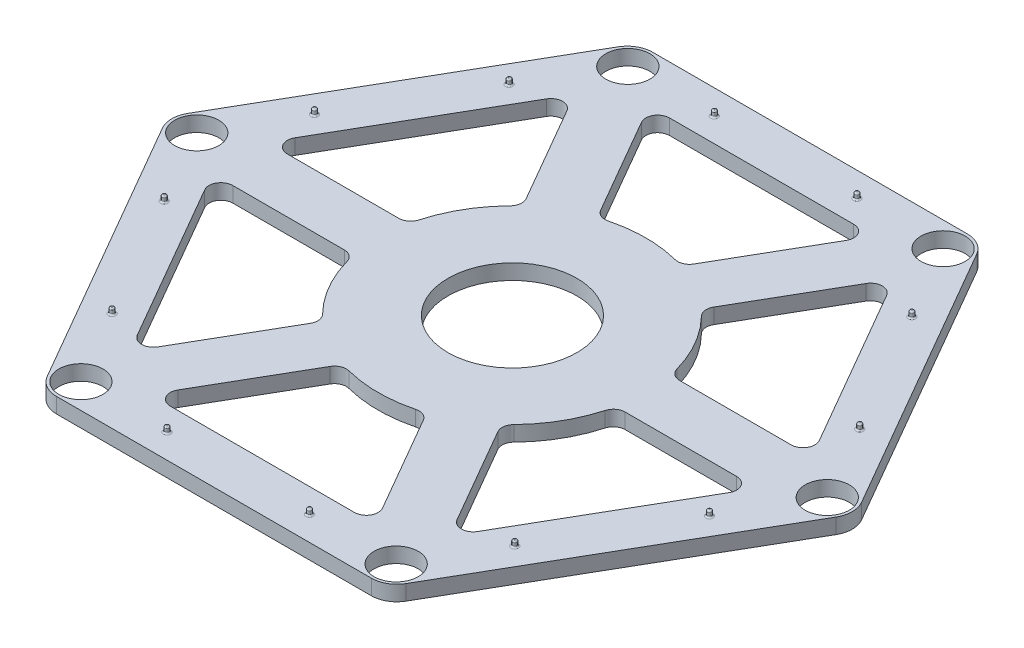
from build123d import *

# Parameters (mm, degrees)
SKETCH1_R           = 2.6
SKETCH1_R_2         = 7.6
BOSS_EXTRUDE1_DEPTH = 1.8
FILLET1_R           = 3
FILLET2_R           = 1.4
SCALE1_SCALE        = 1.15
SKETCH4_R           = 0.3
BOSS_EXTRUDE3_DEPTH = 0.8
FILLET5_R           = 0.2


with BuildPart() as part:
    # Sketch1 → Boss-Extrude1 (new body)
    with BuildSketch(Plane(origin=(0, 0, 0), x_dir=(1, 0, 0), z_dir=(0, 1, 0))):
        Polygon((20.3, 35.160631394), (-20.3, 35.160631394), (-40.6, 0), (-20.3, -35.160631394), (20.3, -35.160631394), (40.6, 0), align=None)
        with Locations((-18.636201283, -32.21652123)):
            Circle(SKETCH1_R, mode=Mode.SUBTRACT)
        with Locations((18.582225165, -32.247684356)):
            Circle(SKETCH1_R, mode=Mode.SUBTRACT)
        with Locations((37.218426448, -0.031163126)):
            Circle(SKETCH1_R, mode=Mode.SUBTRACT)
        with Locations((-37.218426448, 0.031163126)):
            Circle(SKETCH1_R, mode=Mode.SUBTRACT)
        with BuildLine():
            Line((-32.142053523, 3.218057696), (-18.857946477, 26.226806032))
            Line((-18.857946477, 26.226806032), (-10.521325069, 11.78735419))
            ThreePointArc((-10.521325069, 11.78735419), (-13.68320138, 7.9), (-15.468810706, 3.218057696))
            Line((-15.468810706, 3.218057696), (-32.142053523, 3.218057696))
        make_face(mode=Mode.SUBTRACT)
        with BuildLine():
            Line((-18.857946477, -26.226806032), (-32.142053523, -3.218057696))
            Line((-32.142053523, -3.218057696), (-15.468810706, -3.218057696))
            ThreePointArc((-15.468810706, -3.218057696), (-13.68320138, -7.9), (-10.521325069, -11.78735419))
            Line((-10.521325069, -11.78735419), (-18.857946477, -26.226806032))
        make_face(mode=Mode.SUBTRACT)
        with BuildLine():
            Line((13.284107046, -29.444863729), (-13.284107046, -29.444863729))
            Line((-13.284107046, -29.444863729), (-4.947485637, -15.005411886))
            ThreePointArc((-4.947485637, -15.005411886), (0, -15.8), (4.947485637, -15.005411886))
            Line((4.947485637, -15.005411886), (13.284107046, -29.444863729))
        make_face(mode=Mode.SUBTRACT)
        with BuildLine():
            Line((32.142053523, -3.218057696), (18.857946477, -26.226806032))
            Line((18.857946477, -26.226806032), (10.521325069, -11.78735419))
            ThreePointArc((10.521325069, -11.78735419), (13.68320138, -7.9), (15.468810706, -3.218057696))
            Line((15.468810706, -3.218057696), (32.142053523, -3.218057696))
        make_face(mode=Mode.SUBTRACT)
        with BuildLine():
            Line((18.857946477, 26.226806032), (32.142053523, 3.218057696))
            Line((32.142053523, 3.218057696), (15.468810706, 3.218057696))
            ThreePointArc((15.468810706, 3.218057696), (13.68320138, 7.9), (10.521325069, 11.78735419))
            Line((10.521325069, 11.78735419), (18.857946477, 26.226806032))
        make_face(mode=Mode.SUBTRACT)
        with BuildLine():
            Line((-13.284107046, 29.444863729), (13.284107046, 29.444863729))
            Line((13.284107046, 29.444863729), (4.947485637, 15.005411886))
            ThreePointArc((4.947485637, 15.005411886), (0, 15.8), (-4.947485637, 15.005411886))
            Line((-4.947485637, 15.005411886), (-13.284107046, 29.444863729))
        make_face(mode=Mode.SUBTRACT)
        with Locations((-18.582225165, 32.247684356)):
            Circle(SKETCH1_R, mode=Mode.SUBTRACT)
        with Locations((18.636201283, 32.21652123)):
            Circle(SKETCH1_R, mode=Mode.SUBTRACT)
        with Locations((0.052857117, 0)):
            Circle(SKETCH1_R_2, mode=Mode.SUBTRACT)
    extrude(amount=BOSS_EXTRUDE1_DEPTH)

    # Fillet1
    fillet1_edges = [part.edges().sort_by_distance(p)[0] for p in [
        (40.6, 0.9, 0),
        (20.3, 0.9, 35.160631394),
        (-20.3, 0.9, 35.160631394),
        (-40.6, 0.9, 0),
        (-20.3, 0.9, -35.160631394),
        (20.3, 0.9, -35.160631394),
    ]]
    fillet(fillet1_edges, radius=FILLET1_R)

    # Fillet2
    fillet2_edges = [part.edges().sort_by_distance(p)[0] for p in [
        (-32.142053523, 0.9, -3.218057696),
        (-15.468810706, 0.9, -3.218057696),
        (-10.521325069, 0.9, -11.78735419),
        (-18.857946477, 0.9, -26.226806032),
        (-18.857946477, 0.9, 26.226806032),
        (-10.521325069, 0.9, 11.78735419),
        (-15.468810706, 0.9, 3.218057696),
        (-32.142053523, 0.9, 3.218057696),
        (13.284107046, 0.9, 29.444863729),
        (4.947485637, 0.9, 15.005411886),
        (-4.947485637, 0.9, 15.005411886),
        (-13.284107046, 0.9, 29.444863729),
        (32.142053523, 0.9, 3.218057696),
        (15.468810706, 0.9, 3.218057696),
        (10.521325069, 0.9, 11.78735419),
        (18.857946477, 0.9, 26.226806032),
        (18.857946477, 0.9, -26.226806032),
        (10.521325069, 0.9, -11.78735419),
        (15.468810706, 0.9, -3.218057696),
        (32.142053523, 0.9, -3.218057696),
        (-13.284107046, 0.9, -29.444863729),
        (-4.947485637, 0.9, -15.005411886),
        (4.947485637, 0.9, -15.005411886),
        (13.284107046, 0.9, -29.444863729),
    ]]
    fillet(fillet2_edges, radius=FILLET2_R)


with BuildPart() as part_1:
    # Scale1: scaled about (-0.003928135, 0.9, 0)
    add(part.part.scale(SCALE1_SCALE).moved(Location((0.00058922, -0.135, 0))))

    # Sketch4 → Boss-Extrude3 (add)
    with BuildSketch(Plane(origin=(0, 1.935, 0), x_dir=(1, 0, 0), z_dir=(0, 1, 0))):
        with Locations((-9.666353585, 37.12514511)):
            Circle(SKETCH4_R)
        with Locations((9.666353585, 37.12514511)):
            Circle(SKETCH4_R)
        with Locations((27.318141992, 26.933880322)):
            Circle(SKETCH4_R)
        with Locations((36.984495577, 10.191264788)):
            Circle(SKETCH4_R)
        with Locations((36.984495577, -10.191264788)):
            Circle(SKETCH4_R)
        with Locations((27.318141992, -26.933880322)):
            Circle(SKETCH4_R)
        with Locations((9.666353585, -37.12514511)):
            Circle(SKETCH4_R)
        with Locations((-9.666353585, -37.12514511)):
            Circle(SKETCH4_R)
        with Locations((-27.318141992, -26.933880322)):
            Circle(SKETCH4_R)
        with Locations((-36.984495577, -10.191264788)):
            Circle(SKETCH4_R)
        with Locations((-36.984495577, 10.191264788)):
            Circle(SKETCH4_R)
        with Locations((-27.318141992, 26.933880322)):
            Circle(SKETCH4_R)
    extrude(amount=BOSS_EXTRUDE3_DEPTH)

    # Fillet5
    fillet5_edges = [part_1.edges().sort_by_distance(p)[0] for p in [
        (-9.966353585, 1.935, -37.12514511),
        (-9.966353585, 2.735, -37.12514511),
        (9.366353585, 1.935, -37.12514511),
        (9.366353585, 2.735, -37.12514511),
        (27.018141992, 1.935, -26.933880322),
        (27.018141992, 2.735, -26.933880322),
        (36.684495577, 1.935, -10.191264788),
        (36.684495577, 2.735, -10.191264788),
        (36.684495577, 1.935, 10.191264788),
        (36.684495577, 2.735, 10.191264788),
        (27.018141992, 1.935, 26.933880322),
        (27.018141992, 2.735, 26.933880322),
        (9.366353585, 1.935, 37.12514511),
        (9.366353585, 2.735, 37.12514511),
        (-9.966353585, 1.935, 37.12514511),
        (-9.966353585, 2.735, 37.12514511),
        (-27.618141992, 1.935, 26.933880322),
        (-27.618141992, 2.735, 26.933880322),
        (-37.284495577, 1.935, 10.191264788),
        (-37.284495577, 2.735, 10.191264788),
        (-37.284495577, 1.935, -10.191264788),
        (-37.284495577, 2.735, -10.191264788),
        (-27.618141992, 1.935, -26.933880322),
        (-27.618141992, 2.735, -26.933880322),
    ]]
    fillet(fillet5_edges, radius=FILLET5_R)


solid = part_1.part
